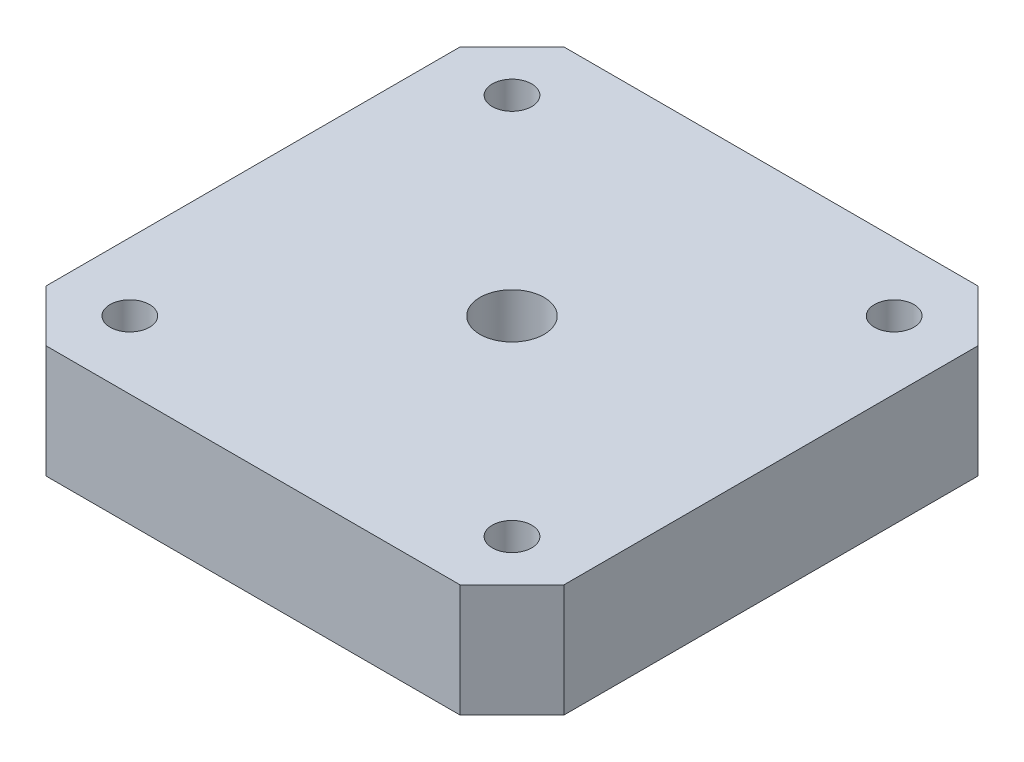
from build123d import *

# Parameters (mm, degrees)
SKETCH_1_W          = 42
SKETCH_1_H          = 42
SKETCH_1_R          = 1.6
SKETCH_1_R_2        = 2.6
EXTRUDE_1_DEPTH     = 9.15
SKETCH_2_R          = 5.15
CUT_EXTRUDE_1_DEPTH = 0.6
CHAMFER_1_SIZE      = 4.2
SKETCH_3_R          = 4.6
CUT_EXTRUDE_2_DEPTH = 3


with BuildPart() as part:
    # 草图1 → 凸台-拉伸1 (new body)
    with BuildSketch(Plane(origin=(0, 0, 0), x_dir=(1, 0, 0), z_dir=(0, 1, 0))):
        Rectangle(SKETCH_1_W, SKETCH_1_H)
        with Locations((-15.5, 15.5)):
            Circle(SKETCH_1_R, mode=Mode.SUBTRACT)
        with Locations((15.5, 15.5)):
            Circle(SKETCH_1_R, mode=Mode.SUBTRACT)
        with Locations((15.5, -15.5)):
            Circle(SKETCH_1_R, mode=Mode.SUBTRACT)
        with Locations((-15.5, -15.5)):
            Circle(SKETCH_1_R, mode=Mode.SUBTRACT)
        Circle(SKETCH_1_R_2, mode=Mode.SUBTRACT)
    extrude(amount=EXTRUDE_1_DEPTH)

    # 草图2 → 切除-拉伸1 (cut)
    with BuildSketch(Plane.XZ):
        Circle(SKETCH_2_R)
    extrude(amount=-CUT_EXTRUDE_1_DEPTH, mode=Mode.SUBTRACT)

    # 倒角1
    chamfer_1_edges = [part.edges().sort_by_distance(p)[0] for p in [
        (21, 4.575, 21),
        (-21, 4.575, 21),
        (-21, 4.575, -21),
        (21, 4.575, -21),
    ]]
    chamfer(chamfer_1_edges, length=CHAMFER_1_SIZE)

    # 草图3 → 切除-拉伸2 (cut)
    with BuildSketch(Plane.XZ.offset(-0.6)):
        Circle(SKETCH_3_R)
    extrude(amount=-CUT_EXTRUDE_2_DEPTH, mode=Mode.SUBTRACT)


solid = part.part
